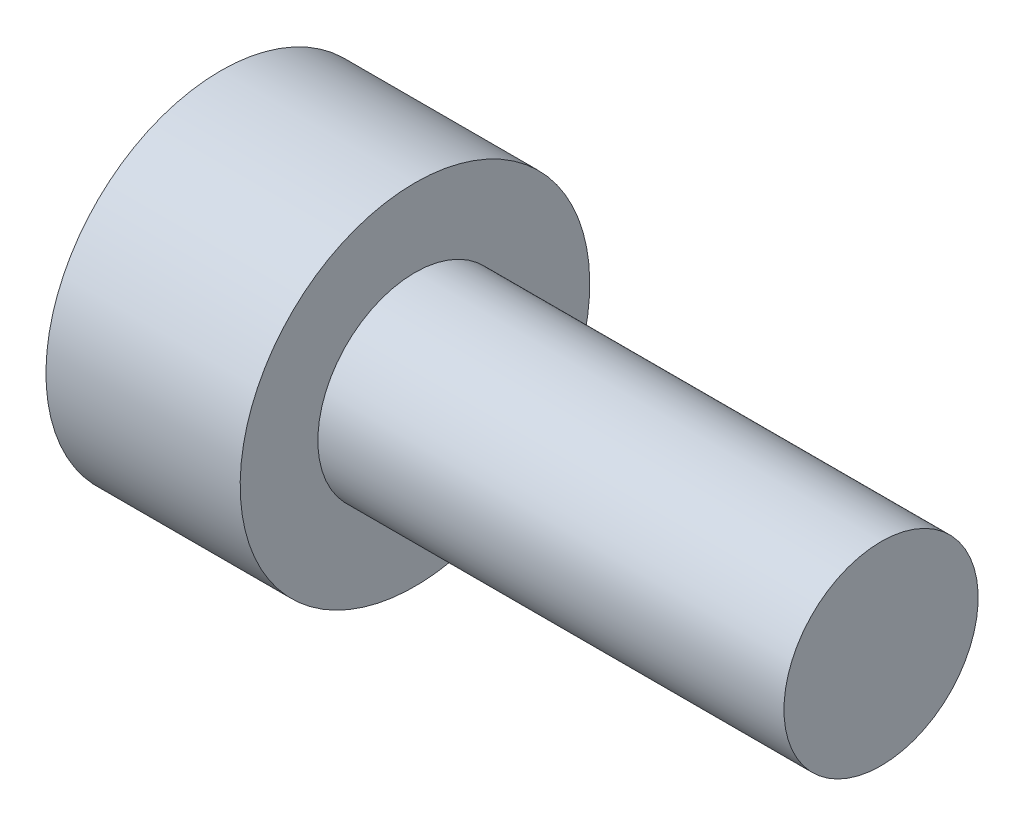
from build123d import *

# Parameters (mm, degrees)
CUT_EXTRUDE1_DEPTH = 1.5


with BuildPart() as part:
    # Sketch1 → Revolve1 (revolve)
    with BuildSketch(Plane.XY):
        Polygon((0, 0), (0, 2.25), (2.5, 2.25), (2.5, 1.25), (8.5, 1.25), (8.5, 0), align=None)
    revolve(axis=Axis((8.5, 0, 0), (-1, 0, 0)))

    # Sketch2 → Cut-Extrude1 (cut)
    with BuildSketch(Plane.ZY):
        Polygon((1.154700538, 0), (0.577350269, 1), (-0.577350269, 1), (-1.154700538, 0), (-0.577350269, -1), (0.577350269, -1), align=None)
    extrude(amount=-CUT_EXTRUDE1_DEPTH, mode=Mode.SUBTRACT)


solid = part.part
